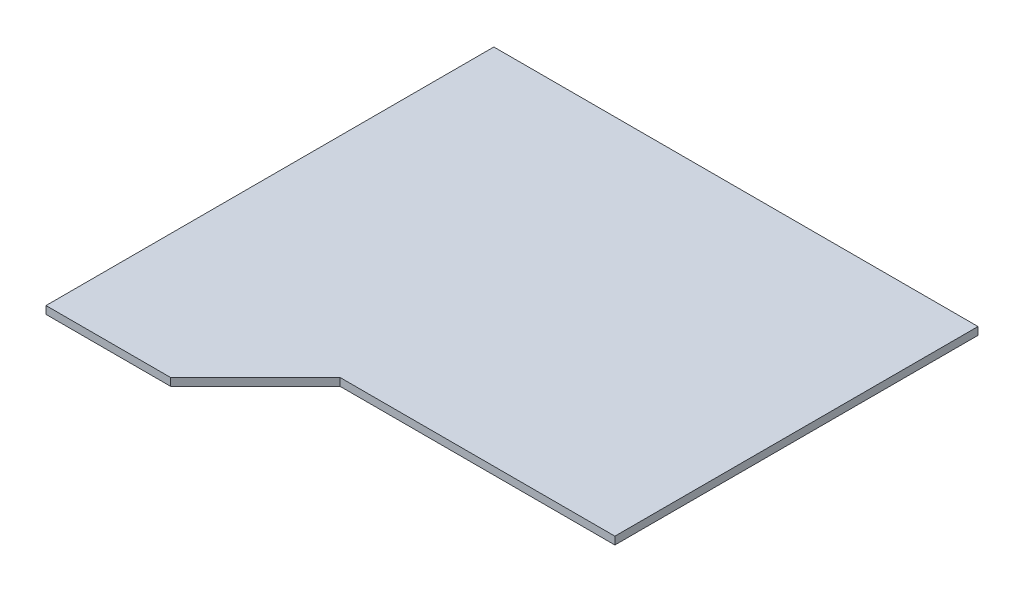
from build123d import *

# Parameters (mm, degrees)
BOSS_EXTRUDE1_DEPTH = 1.5875


with BuildPart() as part:
    # Sketch1 → Boss-Extrude1 (new body)
    with BuildSketch(Plane(origin=(0, 0, 0), x_dir=(1, 0, 0), z_dir=(0, 1, 0))):
        Polygon((0, 0), (25.75, 0), (43.25, 17.5), (100, 17.5), (100, 92.5), (0, 92.5), align=None)
    extrude(amount=BOSS_EXTRUDE1_DEPTH)


solid = part.part
